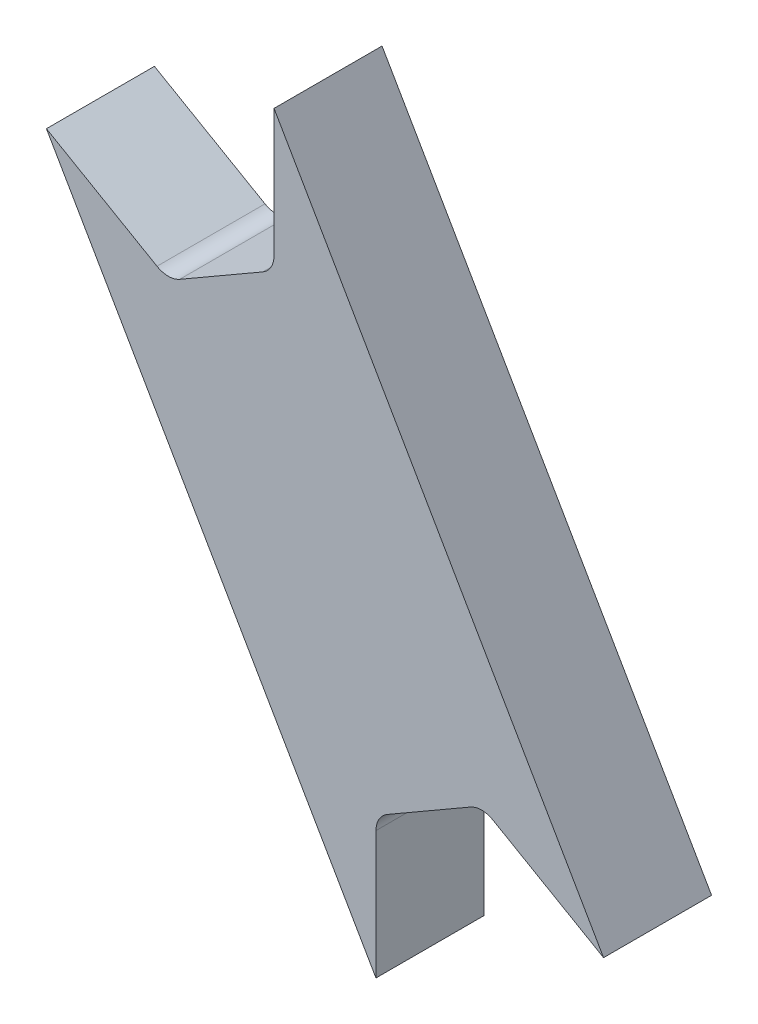
from build123d import *

# Parameters (mm, degrees)
BOSS_EXTRUDE1_DEPTH = 6.35


with BuildPart() as part:
    # Sketch3 → Boss-Extrude1 (new body)
    with BuildSketch(Plane.XY):
        with BuildLine():
            Line((26.127, -29.802243545), (19.627, -26.049466796))
            ThreePointArc((19.627, -26.049466796), (18.96025, -25.870811672), (18.2935, -26.049466796))
            Line((18.2935, -26.049466796), (13.41275, -28.867369122))
            ThreePointArc((13.41275, -28.867369122), (12.924655124, -29.355463998), (12.746, -30.022213998))
            Line((12.746, -30.022213998), (12.746, -37.527767497))
            Line((12.746, -37.527767497), (-6.627, -3.972747202))
            Line((-6.627, -3.972747202), (-0.127, -7.725523952))
            ThreePointArc((-0.127, -7.725523952), (0.53975, -7.904179076), (1.2065, -7.725523952))
            Line((1.2065, -7.725523952), (6.08725, -4.907621626))
            ThreePointArc((6.08725, -4.907621626), (6.575344876, -4.41952675), (6.754, -3.75277675))
            Line((6.754, -3.75277675), (6.754, 3.75277675))
            Line((6.754, 3.75277675), (26.127, -29.802243545))
        make_face()
    extrude(amount=-BOSS_EXTRUDE1_DEPTH)


solid = part.part
